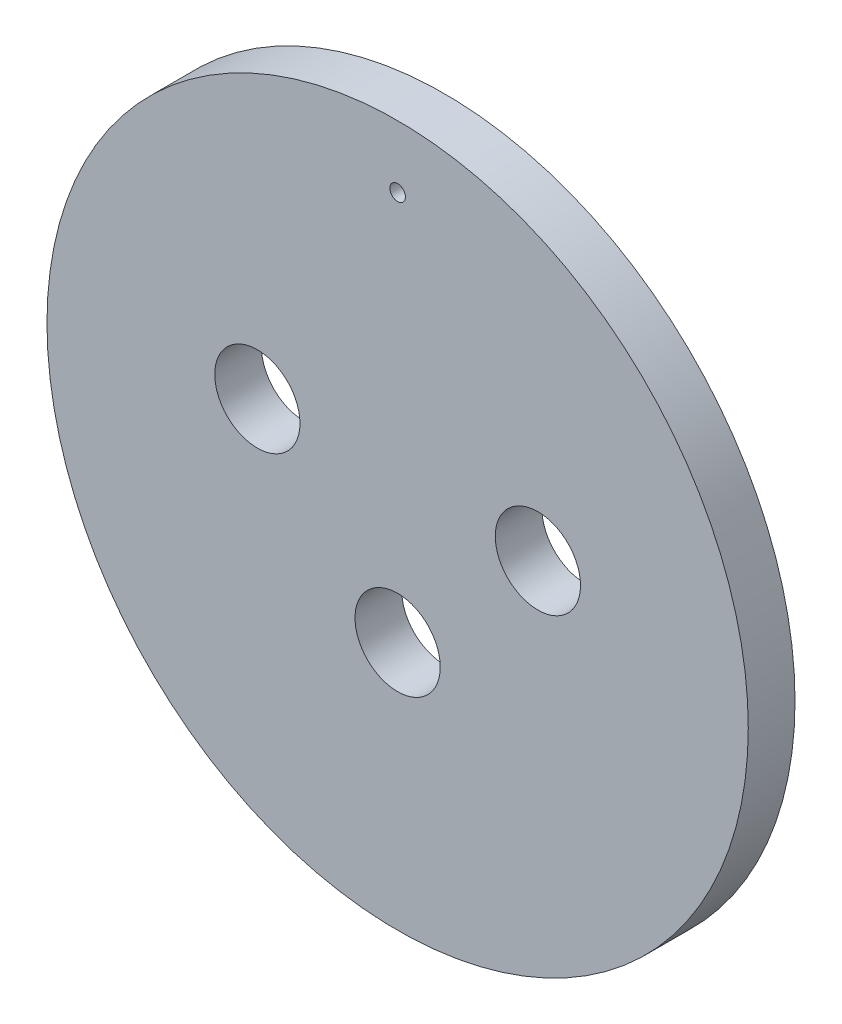
from build123d import *

# Parameters (mm, degrees)
SKETCH1_R           = 22.5
BOSS_EXTRUDE1_DEPTH = 3
SKETCH3_R           = 0.5
SKETCH3_R_2         = 2.735
CUT_EXTRUDE1_DEPTH  = 3


with BuildPart() as part:
    # Sketch1 → Boss-Extrude1 (new body)
    with BuildSketch(Plane.XY):
        Circle(SKETCH1_R)
    extrude(amount=BOSS_EXTRUDE1_DEPTH)

    # Sketch3 → Cut-Extrude1 (cut)
    with BuildSketch(Plane.XY.offset(3)):
        with Locations((0, 18.5)):
            Circle(SKETCH3_R)
        with Locations((0, -6.5)):
            Circle(SKETCH3_R_2)
        with Locations((9, 2.535)):
            Circle(SKETCH3_R_2)
        with Locations((-9, 2.535)):
            Circle(SKETCH3_R_2)
    extrude(amount=-CUT_EXTRUDE1_DEPTH, mode=Mode.SUBTRACT)


solid = part.part
